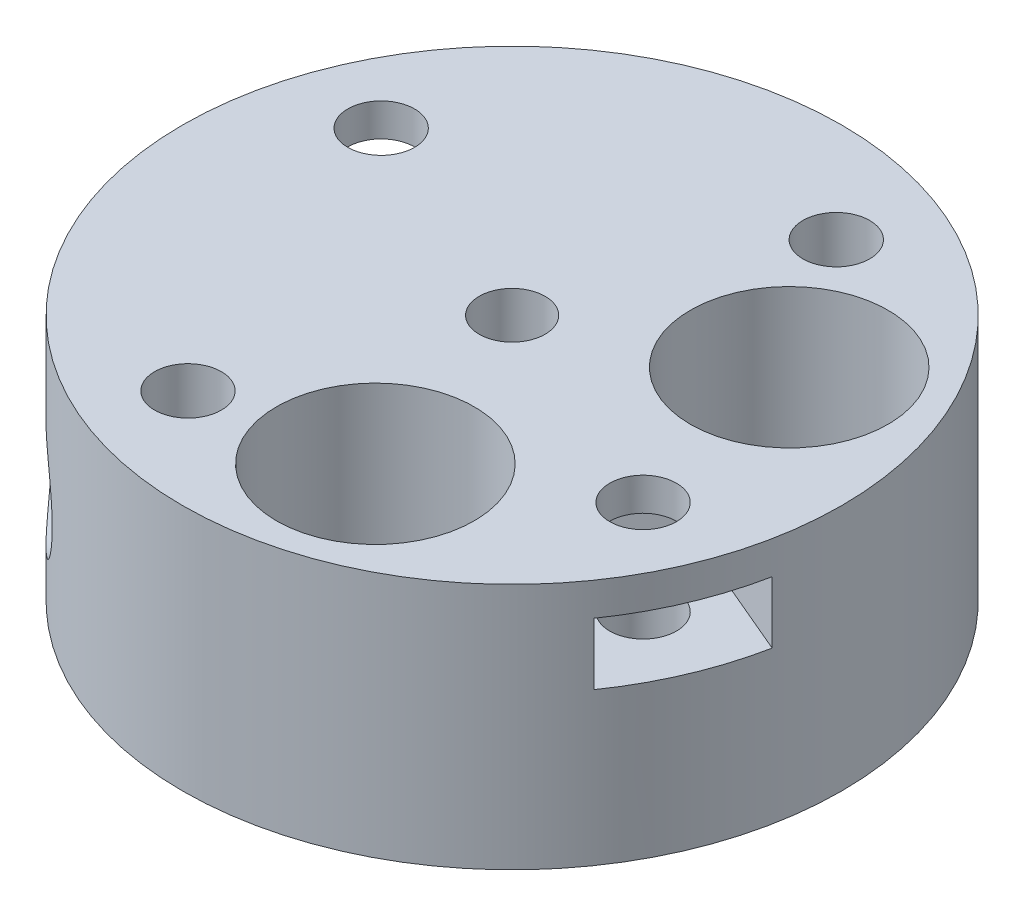
from build123d import *

# Parameters (mm, degrees)
SKETCH1_R               = 20
BOSS_EXTRUDE1_DEPTH     = 7.5
SKETCH4_R               = 5.125
CUT_EXTRUDE2_DEPTH      = 12.15
SKETCH5_R               = 2
CUT_EXTRUDE3_DEPTH      = 1
CUT_EXTRUDE3_DEPTH_BACK = 16
SKETCH2_R               = 2.025
CUT_EXTRUDE1_DEPTH      = 16
CIRPATTERN1_COUNT       = 4
SKETCH6_R               = 1.525
CUT_EXTRUDE4_DEPTH      = 21
CUT_EXTRUDE5_START      = -20
SKETCH7_R               = 3.25
CUT_EXTRUDE5_DEPTH      = 8
CUT_EXTRUDE11_START     = -6.5
CUT_EXTRUDE11_DEPTH     = 2.85
CIRPATTERN2_COUNT       = 2
CIRPATTERN2_ANGLE       = 135
CUT_EXTRUDE7_START      = 5.5
CUT_EXTRUDE7_DEPTH      = 3.75
CIRPATTERN3_COUNT       = 2
CUT_EXTRUDE12_START     = -16.0000001
SKETCH10_R              = 6
CUT_EXTRUDE12_DEPTH     = 17.0000002
CIRPATTERN4_COUNT       = 2
CIRPATTERN4_ANGLE       = 100


with BuildPart() as part:
    # Sketch1 → Boss-Extrude1 (new body, symmetric)
    with BuildSketch(Plane(origin=(0, 0, 0), x_dir=(1, 0, 0), z_dir=(0, 1, 0))):
        Circle(SKETCH1_R)
    extrude(amount=BOSS_EXTRUDE1_DEPTH, both=True)

    # Sketch4 → Cut-Extrude2 (cut)
    with BuildSketch(Plane.XZ.offset(7.5)):
        Circle(SKETCH4_R)
    extrude(amount=-CUT_EXTRUDE2_DEPTH, mode=Mode.SUBTRACT)

    # Sketch5 → Cut-Extrude3 (cut, two sides)
    with BuildSketch(Plane(origin=(0, 7.5, 0), x_dir=(1, 0, 0), z_dir=(0, 1, 0))) as cut_extrude3_sk:
        Circle(SKETCH5_R)
    extrude(amount=CUT_EXTRUDE3_DEPTH, mode=Mode.SUBTRACT)
    extrude(cut_extrude3_sk.sketch, amount=-CUT_EXTRUDE3_DEPTH_BACK, mode=Mode.SUBTRACT)

    # Sketch2 → Cut-Extrude1 (cut, through all)
    with BuildSketch(Plane(origin=(0, 7.5, 0), x_dir=(1, 0, 0), z_dir=(0, 1, 0))):
        with Locations((-13.807572802, 5.860966927)):
            Circle(SKETCH2_R)
    cut_extrude1 = extrude(amount=-CUT_EXTRUDE1_DEPTH, mode=Mode.SUBTRACT)

    # CirPattern1: Cut-Extrude1 ×4 about axis
    cirpattern1_axis = Axis((0, 0, 0), (0, 1, 0))
    for i in range(1, CIRPATTERN1_COUNT):
        add(cut_extrude1.rotate(cirpattern1_axis, i * 360 / CIRPATTERN1_COUNT), mode=Mode.SUBTRACT)

    # Sketch6 → Cut-Extrude4 (cut, through all)
    with BuildSketch(Plane.XY):
        with Locations((0, -1.35)):
            Circle(SKETCH6_R)
    cut_extrude4 = extrude(amount=-CUT_EXTRUDE4_DEPTH, mode=Mode.SUBTRACT)

    # Sketch7 → Cut-Extrude5 (cut)
    with BuildSketch(Plane.XY.offset(CUT_EXTRUDE5_START)):
        with Locations((0, -1.35)):
            Circle(SKETCH7_R)
    cut_extrude5 = extrude(amount=CUT_EXTRUDE5_DEPTH, mode=Mode.SUBTRACT)

    # Sketch9 → Cut-Extrude11 (cut)
    with BuildSketch(Plane.XY.offset(CUT_EXTRUDE11_START)):
        Polygon((3.125, -3.154219591), (3.125, 0.454219591), (0, 2.258439182), (-3.125, 0.454219591), (-3.125, -3.154219591), (-3.125, -7.670640979), (3.125, -7.670640979), align=None)
    cut_extrude11 = extrude(amount=-CUT_EXTRUDE11_DEPTH, mode=Mode.SUBTRACT)

    # CirPattern2: Cut-Extrude4, Cut-Extrude5, Cut-Extrude11 ×2 about axis
    cirpattern2_axis = Axis((0, 0, 0), (0, 1, 0))
    for i in range(1, CIRPATTERN2_COUNT):
        add(cut_extrude4.rotate(cirpattern2_axis, i * CIRPATTERN2_ANGLE / (CIRPATTERN2_COUNT - 1)), mode=Mode.SUBTRACT)
        add(cut_extrude5.rotate(cirpattern2_axis, i * CIRPATTERN2_ANGLE / (CIRPATTERN2_COUNT - 1)), mode=Mode.SUBTRACT)
        add(cut_extrude11.rotate(cirpattern2_axis, i * CIRPATTERN2_ANGLE / (CIRPATTERN2_COUNT - 1)), mode=Mode.SUBTRACT)

    # Sketch8 → Cut-Extrude7 (cut)
    with BuildSketch(Plane(origin=(0, 0, 0), x_dir=(1, 0, 0), z_dir=(0, 1, 0)).offset(CUT_EXTRUDE7_START)):
        Polygon((-9.423079571, 3.999859969), (-10.003560281, 8.727495969), (-14.388053512, 10.588602927), (-19.566381078, 12.786672569), (-22.789912888, 5.192507528), (-17.611585322, 2.994437886), (-13.227092091, 1.133330928), align=None)
    cut_extrude7 = extrude(amount=-CUT_EXTRUDE7_DEPTH, mode=Mode.SUBTRACT)

    # CirPattern3: Cut-Extrude7 ×2 about axis
    cirpattern3_axis = Axis((0, 0, 0), (0, 1, 0))
    for i in range(1, CIRPATTERN3_COUNT):
        add(cut_extrude7.rotate(cirpattern3_axis, i * 360 / CIRPATTERN3_COUNT), mode=Mode.SUBTRACT)

    # Sketch10 → Cut-Extrude12 (cut)
    with BuildSketch(Plane(origin=(0, 7.5, 0), x_dir=(1, 0, 0), z_dir=(0, 1, 0)).offset(CUT_EXTRUDE12_START)):
        with Locations((3.654646309, -11.95380945)):
            Circle(SKETCH10_R)
    cut_extrude12 = extrude(amount=CUT_EXTRUDE12_DEPTH, mode=Mode.SUBTRACT)

    # CirPattern4: Cut-Extrude12 ×2 about axis
    cirpattern4_axis = Axis((0, 7.5, 0), (0, 1, 0))
    for i in range(1, CIRPATTERN4_COUNT):
        add(cut_extrude12.rotate(cirpattern4_axis, i * CIRPATTERN4_ANGLE / (CIRPATTERN4_COUNT - 1)), mode=Mode.SUBTRACT)


solid = part.part
